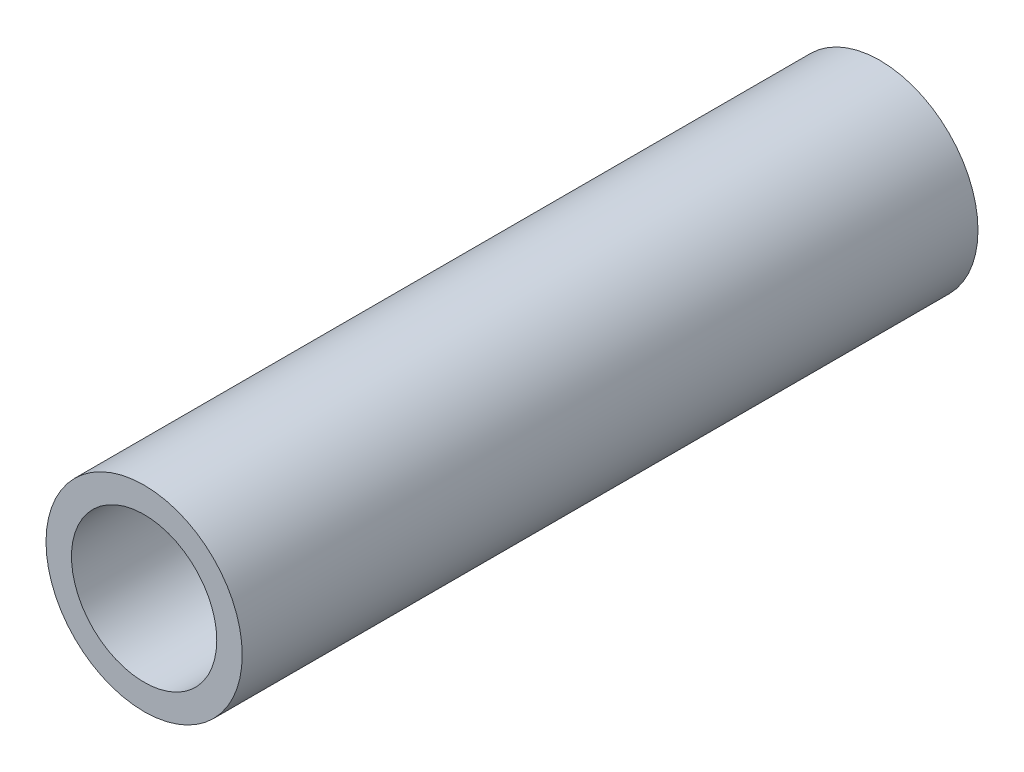
from build123d import *

# Parameters (mm, degrees)
SKETCH1_R           = 10.668
SKETCH1_R_2         = 7.8994
EXTRUDE_THIN1_DEPTH = 40


with BuildPart() as part:
    # Sketch1 → Extrude-Thin1 (new body, symmetric)
    with BuildSketch(Plane.XY):
        Circle(SKETCH1_R)
        Circle(SKETCH1_R_2, mode=Mode.SUBTRACT)
    extrude(amount=EXTRUDE_THIN1_DEPTH, both=True)


solid = part.part
